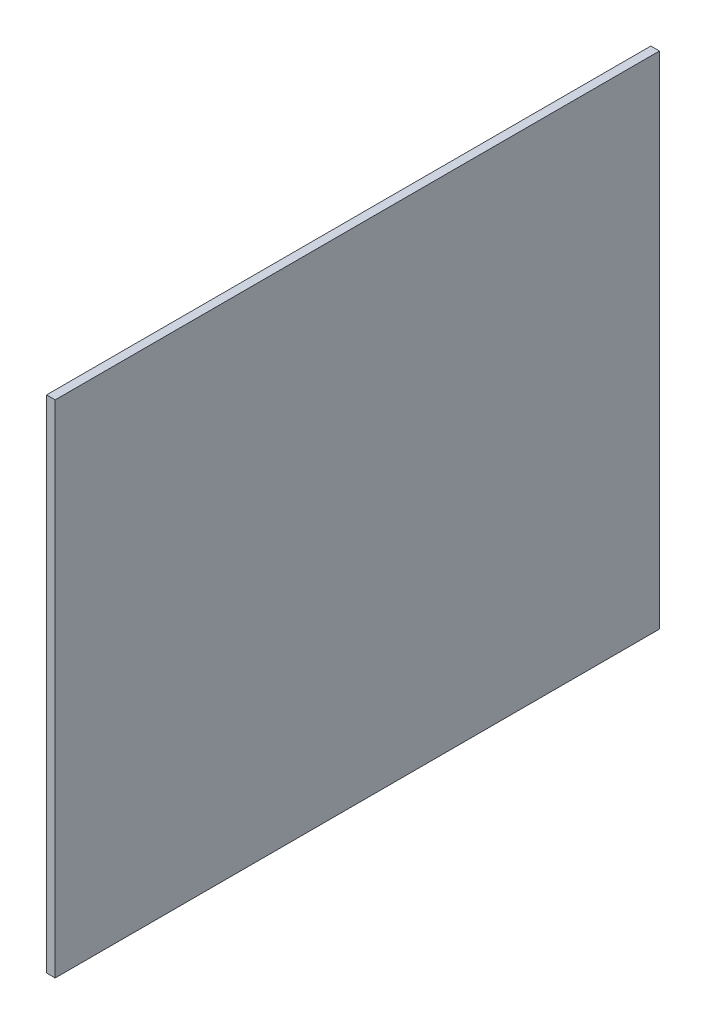
from build123d import *

# Parameters (mm, degrees)
SKETCH_1_W      = 700
SKETCH_1_H      = 580
EXTRUDE_1_DEPTH = 10


with BuildPart() as part:
    # 草图1 → 凸台-拉伸1 (new body)
    with BuildSketch(Plane(origin=(0, 0, 0), x_dir=(0, 0, -1), z_dir=(1, 0, 0))):
        with Locations((350, 290)):
            Rectangle(SKETCH_1_W, SKETCH_1_H)
    extrude(amount=EXTRUDE_1_DEPTH)


solid = part.part
